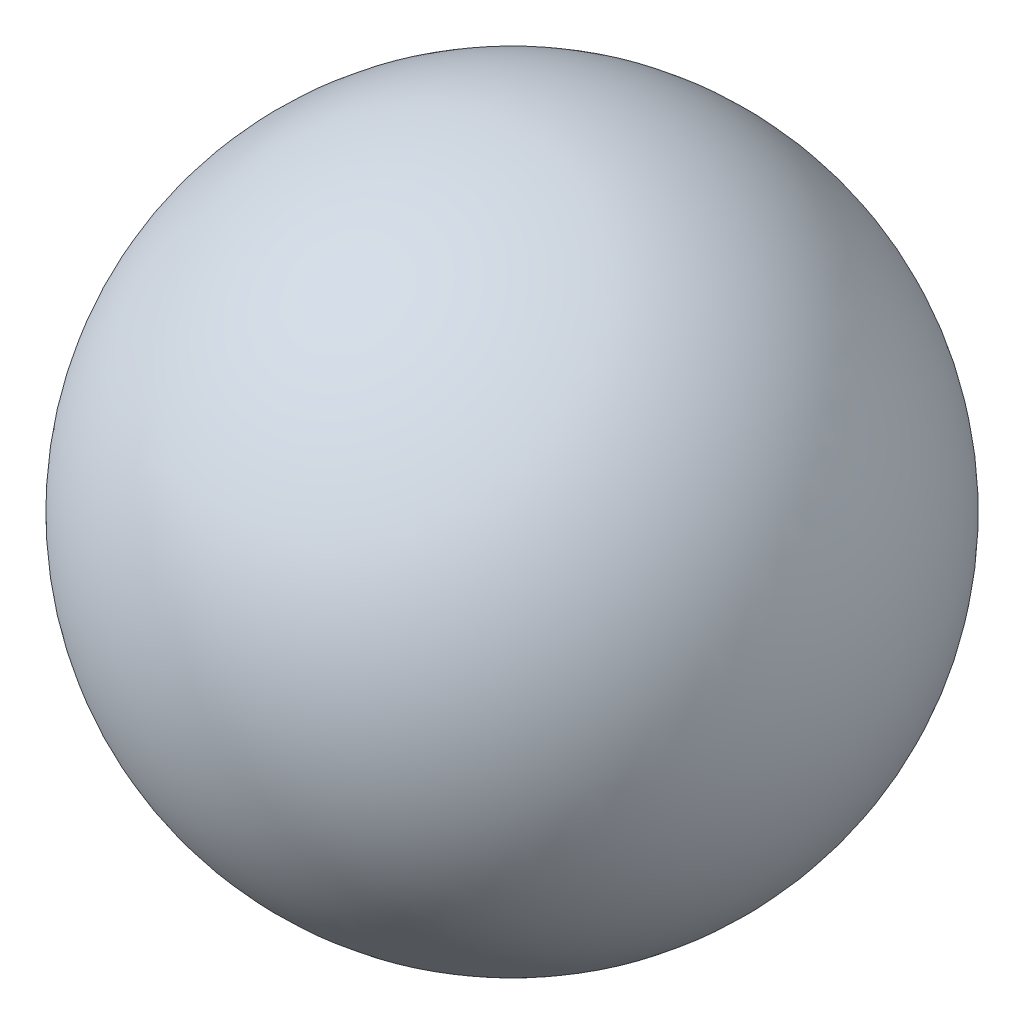
from build123d import *


with BuildPart() as part:
    # Sketch1 → Revolve2 (revolve)
    with BuildSketch(Plane.XY):
        with BuildLine():
            Line((0, 11), (0, -11))
            ThreePointArc((0, -11), (-11, 0), (0, 11))
        make_face()
    revolve(axis=Axis((0, 11, 0), (0, -1, 0)))


solid = part.part
